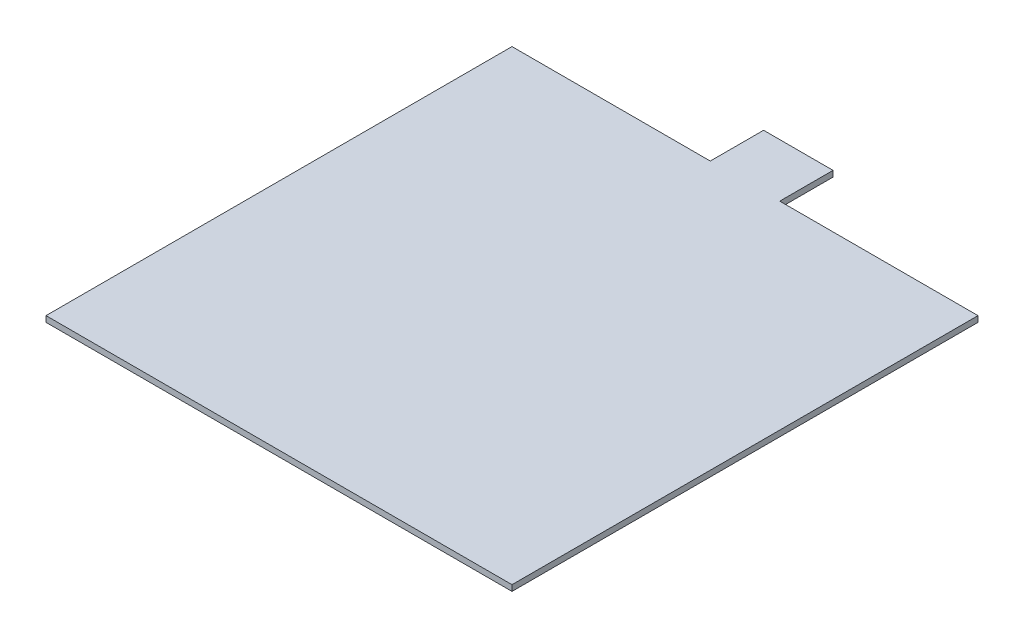
from build123d import *

# Parameters (mm, degrees)
SKETCH1_W           = 43.7
SKETCH1_H           = 43.7
BOSS_EXTRUDE1_DEPTH = 0.55
SKETCH2_W           = 6.512763492
SKETCH2_H           = 5
BOSS_EXTRUDE2_DEPTH = 0.55


with BuildPart() as part:
    # Sketch1 → Boss-Extrude1 (new body)
    with BuildSketch(Plane(origin=(0, 0, 0), x_dir=(1, 0, 0), z_dir=(0, 1, 0))):
        Rectangle(SKETCH1_W, SKETCH1_H)
    extrude(amount=BOSS_EXTRUDE1_DEPTH)

    # Sketch2 → Boss-Extrude2 (add)
    with BuildSketch(Plane(origin=(0, 0, 0), x_dir=(1, 0, 0), z_dir=(0, 1, 0))):
        with Locations((0, 24.35)):
            Rectangle(SKETCH2_W, SKETCH2_H)
    extrude(amount=BOSS_EXTRUDE2_DEPTH)


solid = part.part
